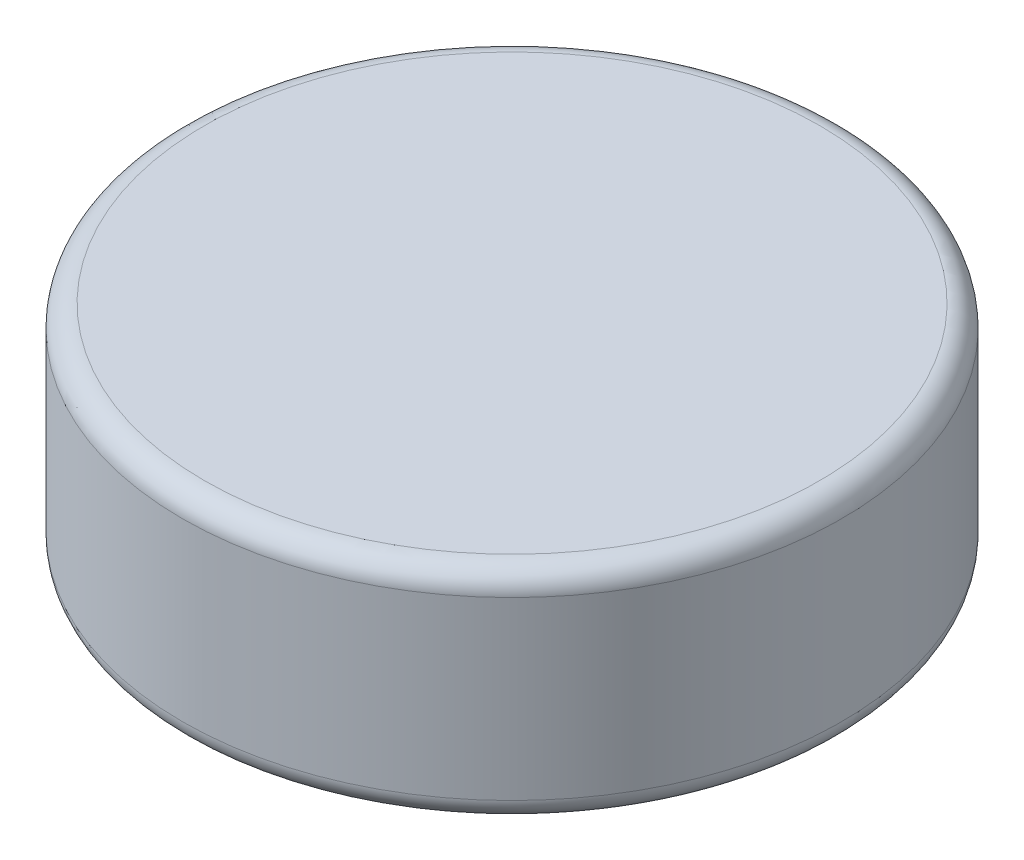
from build123d import *

# Parameters (mm, degrees)
SKETCH1_R           = 3
BOSS_EXTRUDE1_DEPTH = 2
FILLET2_R           = 0.2


with BuildPart() as part:
    # Sketch1 → Boss-Extrude1 (new body)
    with BuildSketch(Plane(origin=(0, 0, 0), x_dir=(1, 0, 0), z_dir=(0, 1, 0))):
        Circle(SKETCH1_R)
    extrude(amount=BOSS_EXTRUDE1_DEPTH)

    # Fillet2
    fillet2_edges = [part.edges().sort_by_distance(p)[0] for p in [
        (-3, 0, 0),
        (-3, 2, 0),
    ]]
    fillet(fillet2_edges, radius=FILLET2_R)


solid = part.part
